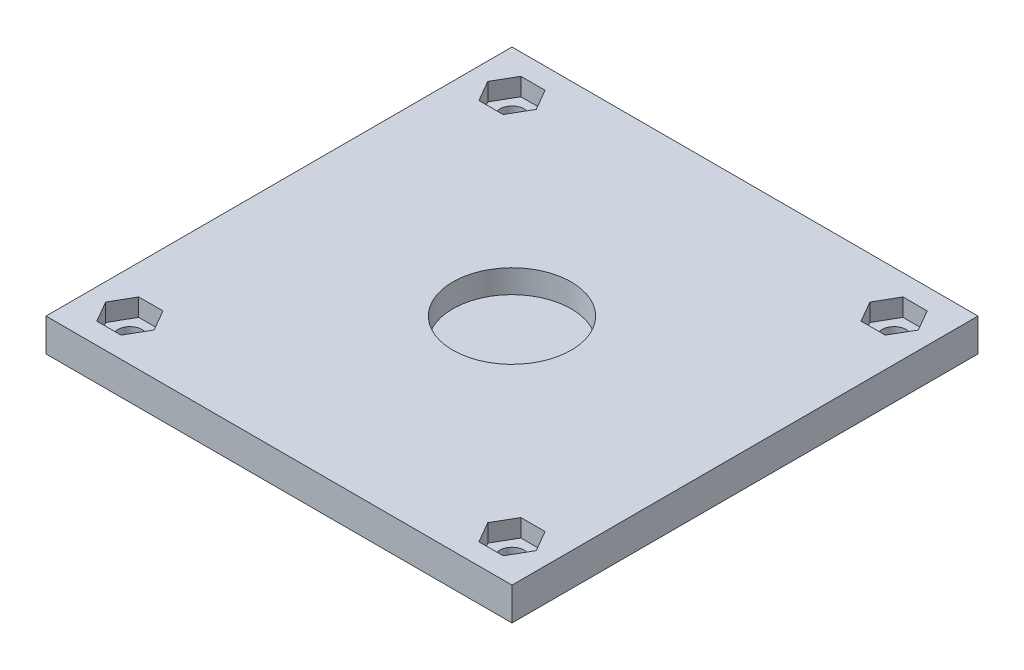
from build123d import *

# Parameters (mm, degrees)
BOSS_EXTRUDE1_DEPTH = 4.476
CUT_EXTRUDE1_DEPTH  = 2.413
SKETCH4_R           = 1.65
CUT_EXTRUDE2_DEPTH  = 5.476
SKETCH5_R           = 8.0645
CUT_EXTRUDE3_DEPTH  = 3.175


with BuildPart() as part:
    # Sketch1 → Boss-Extrude1 (new body)
    with BuildSketch(Plane(origin=(0, 0, 0), x_dir=(1, 0, 0), z_dir=(0, 1, 0))):
        Polygon((8.13035809, -26.001312997), (71.63035809, -26.001312997), (71.63035809, -13.301312997), (71.63035809, 15.908687003), (71.63035809, 37.498687003), (8.13035809, 37.498687003), (8.13035809, 22.258687003), (8.13035809, -19.651312997), align=None)
    extrude(amount=BOSS_EXTRUDE1_DEPTH)

    # Sketch2 → Cut-Extrude1 (cut)
    with BuildSketch(Plane(origin=(0, 4.476, 0), x_dir=(1, 0, 0), z_dir=(0, 1, 0))):
        Polygon((64.265579696, 28.926187003), (67.565136484, 28.926187003), (69.214914879, 31.783687003), (67.565136484, 34.641187003), (64.265579696, 34.641187003), (62.615801302, 31.783687003), align=None)
        Polygon((17.144914879, 31.783687003), (15.495136484, 34.641187003), (12.195579696, 34.641187003), (10.545801302, 31.783687003), (12.195579696, 28.926187003), (15.495136484, 28.926187003), align=None)
        Polygon((64.265579696, -23.143812997), (67.565136484, -23.143812997), (69.214914879, -20.286312997), (67.565136484, -17.428812997), (64.265579696, -17.428812997), (62.615801302, -20.286312997), align=None)
        Polygon((12.195579696, -23.143812997), (15.495136484, -23.143812997), (17.144914879, -20.286312997), (15.495136484, -17.428812997), (12.195579696, -17.428812997), (10.545801302, -20.286312997), align=None)
    extrude(amount=-CUT_EXTRUDE1_DEPTH, mode=Mode.SUBTRACT)

    # Sketch4 → Cut-Extrude2 (cut, through all)
    with BuildSketch(Plane(origin=(0, 4.476, 0), x_dir=(1, 0, 0), z_dir=(0, 1, 0))):
        with Locations((65.91535809, 31.783687003)):
            Circle(SKETCH4_R)
        with Locations((13.84535809, 31.783687003)):
            Circle(SKETCH4_R)
        with Locations((65.91535809, -20.286312997)):
            Circle(SKETCH4_R)
        with Locations((13.84535809, -20.286312997)):
            Circle(SKETCH4_R)
    extrude(amount=-CUT_EXTRUDE2_DEPTH, mode=Mode.SUBTRACT)

    # Sketch5 → Cut-Extrude3 (cut)
    with BuildSketch(Plane(origin=(0, 4.476, 0), x_dir=(1, 0, 0), z_dir=(0, 1, 0))):
        with Locations((39.88035809, 5.748687003)):
            Circle(SKETCH5_R)
    extrude(amount=-CUT_EXTRUDE3_DEPTH, mode=Mode.SUBTRACT)


solid = part.part
